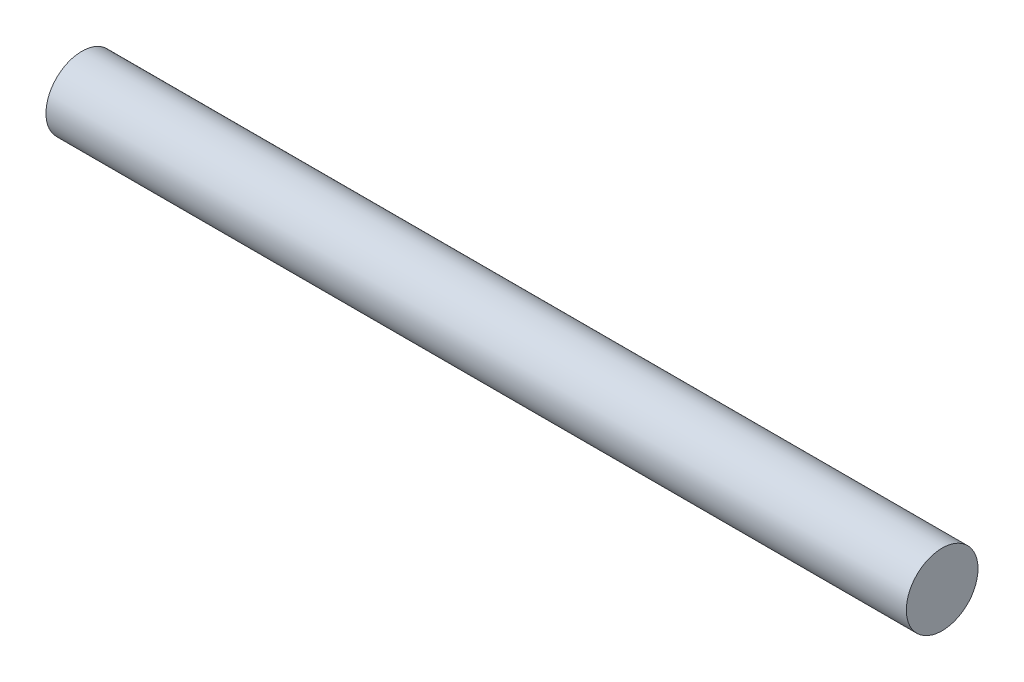
from build123d import *

# Parameters (mm, degrees)
SKETCH1_R           = 2.5
BOSS_EXTRUDE1_DEPTH = 30


with BuildPart() as part:
    # Sketch1 → Boss-Extrude1 (new body, symmetric)
    with BuildSketch(Plane(origin=(0, 0, 0), x_dir=(0, 0, -1), z_dir=(1, 0, 0))):
        Circle(SKETCH1_R)
    extrude(amount=BOSS_EXTRUDE1_DEPTH, both=True)


solid = part.part
